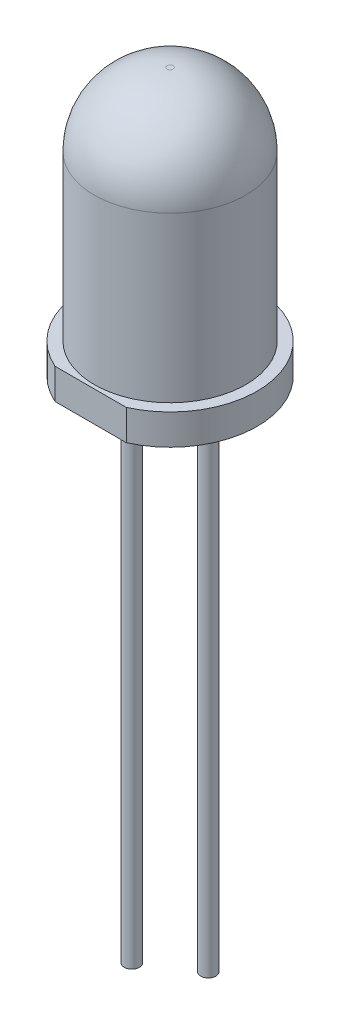
from build123d import *

# Parameters (mm, degrees)
CUT_EXTRUDE1_DEPTH  = 1
SKETCH3_R           = 0.25
BOSS_EXTRUDE1_DEPTH = 16
SKETCH4_R           = 0.25
BOSS_EXTRUDE2_DEPTH = 1.5


with BuildPart() as part:
    # Sketch1 → Revolve1 (revolve)
    with BuildSketch(Plane.XY):
        with BuildLine():
            Line((0, 0), (0, 8.75))
            Line((0, 8.75), (0.1, 8.75))
            ThreePointArc((0.1, 8.75), (1.782914139, 8.052914139), (2.48, 6.37))
            Line((2.48, 6.37), (2.48, 1))
            Line((2.48, 1), (2.85, 1))
            Line((2.85, 1), (2.85, 0))
            Line((2.85, 0), (0, 0))
        make_face()
    revolve(axis=Axis((0, 0, 0), (0, 1, 0)))

    # Sketch2 → Cut-Extrude1 (cut)
    with BuildSketch(Plane.XZ):
        with BuildLine():
            Line((-1.167261753, 2.6), (1.167261753, 2.6))
            ThreePointArc((1.167261753, 2.6), (0, 2.85), (-1.167261753, 2.6))
        make_face()
    extrude(amount=-CUT_EXTRUDE1_DEPTH, mode=Mode.SUBTRACT)

    # Sketch3 → Boss-Extrude1 (add)
    with BuildSketch(Plane.XZ):
        with Locations((0, -1.25)):
            Circle(SKETCH3_R)
        with Locations((0, 1.25)):
            Circle(SKETCH3_R)
    extrude(amount=BOSS_EXTRUDE1_DEPTH)

    # Sketch4 → Boss-Extrude2 (add)
    with BuildSketch(Plane.XZ.offset(16)):
        with Locations((0, -1.25)):
            Circle(SKETCH4_R)
    extrude(amount=BOSS_EXTRUDE2_DEPTH)


solid = part.part
